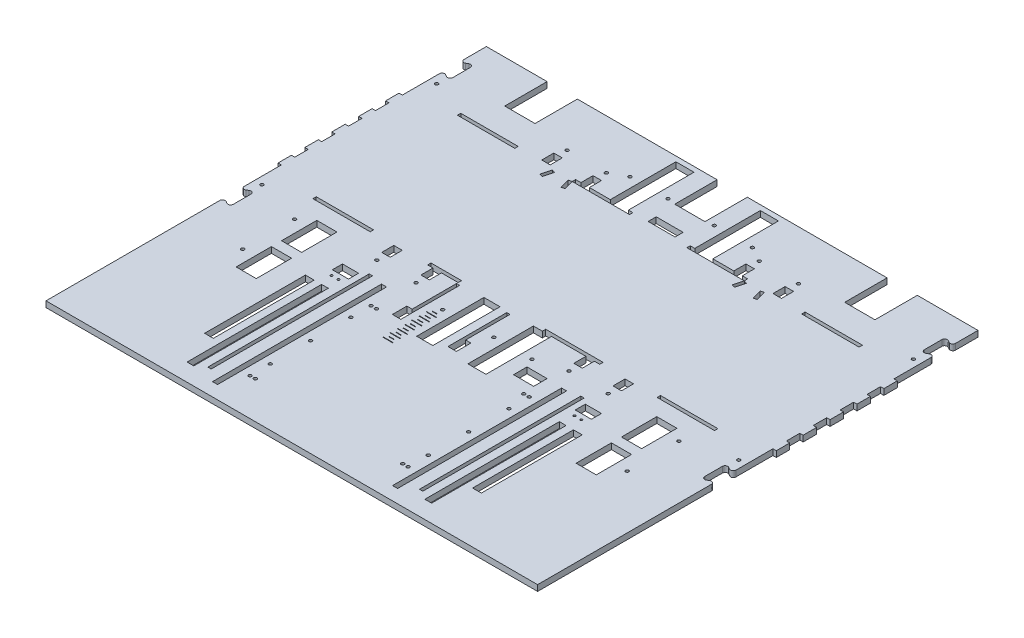
from build123d import *

# Parameters (mm, degrees)
SKETCH1_W                  = 54.186666667
SKETCH1_H                  = 3.175
SKETCH1_W_2                = 54.186666666
SKETCH1_W_3                = 3.175
SKETCH1_H_2                = 12.7
MAIN_EXTRUDE_DEPTH         = 5.588
SKETCH3_W                  = 25.484666667
SKETCH3_H                  = 3.175
UNDER_TROUGH_FILL_DEPTH    = 5.588
SKETCH4_R                  = 1.499997
SKETCH4_W                  = 12.7
SKETCH4_H                  = 3.175
SKETCH4_W_2                = 17.1
SKETCH4_H_2                = 61.9125
LEVER_HOLES_DEPTH          = 6.588
SKETCH5_W                  = 15.24
SKETCH5_H                  = 63.5
SKETCH5_W_2                = 0.15
SKETCH5_H_2                = 3.175
SKETCH5_R                  = 1.5
TROUGH_SLOT_DEPTH          = 6.588
SKETCH6_R                  = 1.05
SKETCH6_W                  = 15.24
SKETCH6_H                  = 9.525
CLOSE_SWITCH_HOLES_DEPTH   = 6.588
SKETCH7_W                  = 9.525
SKETCH7_H                  = 0.508
SKETCH7_W_2                = 4.7625
TROUGH_MEASUREMENT_DEPTH   = 6.588
SKETCH8_W                  = 19.05
SKETCH8_H                  = 33.3375
SKETCH8_H_2                = 12.7
SKETCH8_W_2                = 28.575
SKETCH8_H_3                = 40
SKETCH8_W_3                = 25.4
SKETCH8_H_4                = 7.62
WIRE_HOLES_DEPTH           = 6.588
SKETCH9_R                  = 1.5
SKETCH9_W                  = 8
SKETCH9_H                  = 11.43
IR_SLOTS_DEPTH             = 6.588
DOOR_FLANGE_SLOTS_DEPTH    = 6.588
SKETCH12_R                 = 1.5
SKETCH12_W                 = 3.175
SKETCH12_H                 = 12.7
FLOOR_MOUNT_HOLES_DEPTH    = 6.588
EXTENSION_CENTER_CUT_DEPTH = 6.588
SKETCH13_W                 = 464.2612
SKETCH13_H                 = 114.3
CENTER_EXTEND_DEPTH        = 5.588
SKETCH15_W                 = 3.175
SKETCH15_H                 = 152.4
TRACK_CUTS_DEPTH           = 6.588
SKETCH18_R                 = 1.5
SKETCH18_W                 = 4.7752
SKETCH18_H                 = 159.639
SERVO_RACK_HOLES_DEPTH     = 6.588
SKETCH17_W                 = 8.255
SKETCH17_H                 = 95.25
SKETCH17_W_2               = 6.35
SKETCH17_H_2               = 127
SERVO_WIRE_CUTS_DEPTH      = 6.588
SKETCH19_R                 = 1.5
PI_MOUNT_HOLES_DEPTH       = 6.588
SKETCH20_R                 = 1.5
SKETCH20_W                 = 8
SKETCH20_H                 = 11.43
IR2_DEPTH                  = 5.588


with BuildPart() as part:
    # Sketch1 → Main Extrude (new body)
    with BuildSketch(Plane(origin=(0, 0, 0), x_dir=(1, 0, 0), z_dir=(0, 1, 0))):
        Polygon((406.4, 136.525), (-406.4, 136.525), (-406.4, 69.85), (-352.213333333, 69.85), (-352.213333333, 66.675), (-377.825, 66.675), (-377.825, 57.15), (-381, 57.15), (-381, 66.675), (-406.4, 66.675), (-406.4, -66.675), (-381, -66.675), (-381, -57.15), (-377.825, -57.15), (-377.825, -66.675), (-352.213333333, -66.675), (-352.213333333, -69.85), (-406.4, -69.85), (-406.4, -165.1), (406.4, -165.1), (406.4, -69.85), (352.213333333, -69.85), (352.213333333, -66.675), (377.825, -66.675), (377.825, -57.15), (381, -57.15), (381, -66.675), (406.4, -66.675), (406.4, 66.675), (381, 66.675), (381, 57.15), (377.825, 57.15), (377.825, 66.675), (352.213333333, 66.675), (352.213333333, 69.85), (406.4, 69.85), align=None)
        with Locations((270.933333334, -68.2625)):
            Rectangle(SKETCH1_W, SKETCH1_H, mode=Mode.SUBTRACT)
        with Locations((162.56, -68.2625)):
            Rectangle(SKETCH1_W_2, SKETCH1_H, mode=Mode.SUBTRACT)
        with Locations((54.186666667, -68.2625)):
            Rectangle(SKETCH1_W, SKETCH1_H, mode=Mode.SUBTRACT)
        with Locations((-54.186666667, -68.2625)):
            Rectangle(SKETCH1_W, SKETCH1_H, mode=Mode.SUBTRACT)
        with Locations((-162.56, -68.2625)):
            Rectangle(SKETCH1_W_2, SKETCH1_H, mode=Mode.SUBTRACT)
        with Locations((-270.933333334, -68.2625)):
            Rectangle(SKETCH1_W, SKETCH1_H, mode=Mode.SUBTRACT)
        with Locations((379.4125, -38.1)):
            Rectangle(SKETCH1_W_3, SKETCH1_H_2, mode=Mode.SUBTRACT)
        with Locations((379.4125, -12.7)):
            Rectangle(SKETCH1_W_3, SKETCH1_H_2, mode=Mode.SUBTRACT)
        with Locations((379.4125, 12.7)):
            Rectangle(SKETCH1_W_3, SKETCH1_H_2, mode=Mode.SUBTRACT)
        with Locations((379.4125, 38.1)):
            Rectangle(SKETCH1_W_3, SKETCH1_H_2, mode=Mode.SUBTRACT)
        with Locations((-379.4125, -38.1)):
            Rectangle(SKETCH1_W_3, SKETCH1_H_2, mode=Mode.SUBTRACT)
        with Locations((-379.4125, -12.7)):
            Rectangle(SKETCH1_W_3, SKETCH1_H_2, mode=Mode.SUBTRACT)
        with Locations((-379.4125, 12.7)):
            Rectangle(SKETCH1_W_3, SKETCH1_H_2, mode=Mode.SUBTRACT)
        with Locations((-379.4125, 38.1)):
            Rectangle(SKETCH1_W_3, SKETCH1_H_2, mode=Mode.SUBTRACT)
        with Locations((270.933333334, 68.2625)):
            Rectangle(SKETCH1_W, SKETCH1_H, mode=Mode.SUBTRACT)
        with Locations((162.56, 68.2625)):
            Rectangle(SKETCH1_W_2, SKETCH1_H, mode=Mode.SUBTRACT)
        with Locations((54.186666667, 68.2625)):
            Rectangle(SKETCH1_W, SKETCH1_H, mode=Mode.SUBTRACT)
        with Locations((-54.186666667, 68.2625)):
            Rectangle(SKETCH1_W, SKETCH1_H, mode=Mode.SUBTRACT)
        with Locations((-162.56, 68.2625)):
            Rectangle(SKETCH1_W_2, SKETCH1_H, mode=Mode.SUBTRACT)
        with Locations((-270.933333334, 68.2625)):
            Rectangle(SKETCH1_W, SKETCH1_H, mode=Mode.SUBTRACT)
    extrude(amount=MAIN_EXTRUDE_DEPTH)

    # Sketch3 → Under Trough Fill (add)
    with BuildSketch(Plane(origin=(0, 5.588, 0), x_dir=(1, 0, 0), z_dir=(0, 1, 0))):
        with Locations((-39.835666667, -68.2625)):
            Rectangle(SKETCH3_W, SKETCH3_H)
    extrude(amount=-UNDER_TROUGH_FILL_DEPTH)

    # Sketch4 → Lever Holes (cut, through all)
    with BuildSketch(Plane(origin=(0, 5.588, 0), x_dir=(1, 0, 0), z_dir=(0, 1, 0))):
        with Locations((9.178, -97.7625)):
            Circle(SKETCH4_R)
        with Locations((45.178, -97.7625)):
            Circle(SKETCH4_R)
        with Locations((21.878, 97.7625)):
            Circle(SKETCH4_R)
        with Locations((57.878, 97.7625)):
            Circle(SKETCH4_R)
        with Locations((-21.878, 97.7625)):
            Circle(SKETCH4_R)
        with Locations((-57.878, 97.7625)):
            Circle(SKETCH4_R)
        with Locations((-393.7, -65.0875)):
            Rectangle(SKETCH4_W, SKETCH4_H)
        with Locations((-393.7, 65.0875)):
            Rectangle(SKETCH4_W, SKETCH4_H)
        with Locations((393.7, 65.0875)):
            Rectangle(SKETCH4_W, SKETCH4_H)
        with Locations((393.7, -65.0875)):
            Rectangle(SKETCH4_W, SKETCH4_H)
        with Locations((27.178, -100.80625)):
            Rectangle(SKETCH4_W_2, SKETCH4_H_2)
        with Locations((39.878, 100.80625)):
            Rectangle(SKETCH4_W_2, SKETCH4_H_2)
        with Locations((-39.878, 100.80625)):
            Rectangle(SKETCH4_W_2, SKETCH4_H_2)
    extrude(amount=-LEVER_HOLES_DEPTH, mode=Mode.SUBTRACT)

    # Sketch5 → Trough Slot (cut, through all)
    with BuildSketch(Plane(origin=(0, 5.588, 0), x_dir=(1, 0, 0), z_dir=(0, 1, 0))):
        Polygon((-52.428, -71.4248), (-52.428, -113.3), (-57.428, -113.3), (-57.428, -127), (-49.428, -127), (-49.428, -71.4248), align=None)
        Polygon((-4.928, -127), (3.072, -127), (3.072, -113.3), (-1.928, -113.3), (-1.928, -71.4248), (-4.928, -71.4248), align=None)
        with Locations((-20.498, -101.6)):
            Rectangle(SKETCH5_W, SKETCH5_H)
        with Locations((-52.503, -68.2625)):
            Rectangle(SKETCH5_W_2, SKETCH5_H_2)
        with Locations((-37.568, -99.35)):
            Circle(SKETCH5_R)
    extrude(amount=-TROUGH_SLOT_DEPTH, mode=Mode.SUBTRACT)

    # Sketch6 → Close Switch Holes (cut, through all)
    with BuildSketch(Plane(origin=(0, 5.588, 0), x_dir=(1, 0, 0), z_dir=(0, 1, 0))):
        with Locations((117.9405058, -123.8499876)):
            Circle(SKETCH6_R)
        with Locations((111.4404934, -123.8499876)):
            Circle(SKETCH6_R)
        with Locations((-117.9405058, -123.8499876)):
            Circle(SKETCH6_R)
        with Locations((-111.4404934, -123.8499876)):
            Circle(SKETCH6_R)
        with Locations((-114.6904996, -114.0074876)):
            Rectangle(SKETCH6_W, SKETCH6_H)
        with Locations((114.6904996, -114.0074876)):
            Rectangle(SKETCH6_W, SKETCH6_H)
    extrude(amount=-CLOSE_SWITCH_HOLES_DEPTH, mode=Mode.SUBTRACT)

    # Sketch7 → Trough Measurement (cut, through all)
    with BuildSketch(Plane(origin=(0, 5.588, 0), x_dir=(1, 0, 0), z_dir=(0, 1, 0))):
        with Locations((-38.773, -142.992)):
            Rectangle(SKETCH7_W, SKETCH7_H)
        with Locations((-38.773, -149.85)):
            Rectangle(SKETCH7_W, SKETCH7_H)
        with Locations((-38.773, -146.675)):
            Rectangle(SKETCH7_W_2, SKETCH7_H)
        with Locations((-38.773, -139.817)):
            Rectangle(SKETCH7_W_2, SKETCH7_H)
        with Locations((-38.773, -136.134)):
            Rectangle(SKETCH7_W, SKETCH7_H)
        with Locations((-38.773, -132.959)):
            Rectangle(SKETCH7_W_2, SKETCH7_H)
        with Locations((-38.773, -129.276)):
            Rectangle(SKETCH7_W, SKETCH7_H)
        with Locations((-38.773, -126.101)):
            Rectangle(SKETCH7_W_2, SKETCH7_H)
        with Locations((-38.773, -122.418)):
            Rectangle(SKETCH7_W, SKETCH7_H)
        with Locations((-38.773, -119.243)):
            Rectangle(SKETCH7_W_2, SKETCH7_H)
        with Locations((-38.773, -115.56)):
            Rectangle(SKETCH7_W, SKETCH7_H)
        with Locations((-38.773, -112.385)):
            Rectangle(SKETCH7_W_2, SKETCH7_H)
        with Locations((-38.773, -108.702)):
            Rectangle(SKETCH7_W, SKETCH7_H)
        with Locations((-38.773, -105.527)):
            Rectangle(SKETCH7_W_2, SKETCH7_H)
    extrude(amount=-TROUGH_MEASUREMENT_DEPTH, mode=Mode.SUBTRACT)

    # Sketch8 → Wire Holes (cut, through all)
    with BuildSketch(Plane(origin=(0, 5.588, 0), x_dir=(1, 0, 0), z_dir=(0, 1, 0))):
        with Locations((-160.528, -145.25625)):
            Rectangle(SKETCH8_W, SKETCH8_H)
        with Locations((-160.528, -102.39375)):
            Rectangle(SKETCH8_W, SKETCH8_H)
        with Locations((160.528, -145.25625)):
            Rectangle(SKETCH8_W, SKETCH8_H)
        with Locations((160.528, -102.39375)):
            Rectangle(SKETCH8_W, SKETCH8_H)
        with Locations((58.588, -112.7125)):
            Rectangle(SKETCH8_W, SKETCH8_H_2)
        with Locations((0, 116.525)):
            Rectangle(SKETCH8_W_2, SKETCH8_H_3)
        with Locations((0, 73.66)):
            Rectangle(SKETCH8_W_3, SKETCH8_H_4)
        with Locations((-160.528, 116.525)):
            Rectangle(SKETCH8_W_2, SKETCH8_H_3)
        with Locations((160.528, 116.525)):
            Rectangle(SKETCH8_W_2, SKETCH8_H_3)
    extrude(amount=-WIRE_HOLES_DEPTH, mode=Mode.SUBTRACT)

    # Sketch9 → IR Slots (cut, through all)
    with BuildSketch(Plane(origin=(0, 5.588, 0), x_dir=(1, 0, 0), z_dir=(0, 1, 0))):
        with Locations((109.2096114, -89.85)):
            Circle(SKETCH9_R)
        with Locations((-109.2096114, -89.85)):
            Circle(SKETCH9_R)
        with Locations((109.2096114, 89.85)):
            Circle(SKETCH9_R)
        with Locations((-109.2096114, 89.85)):
            Circle(SKETCH9_R)
        with Locations((-109.2096114, 75.565)):
            Rectangle(SKETCH9_W, SKETCH9_H)
        with Locations((109.2096114, 75.565)):
            Rectangle(SKETCH9_W, SKETCH9_H)
        with Locations((109.2096114, -75.565)):
            Rectangle(SKETCH9_W, SKETCH9_H)
        with Locations((-109.2096114, -75.565)):
            Rectangle(SKETCH9_W, SKETCH9_H)
    extrude(amount=-IR_SLOTS_DEPTH, mode=Mode.SUBTRACT)

    # Sketch10 → Door Flange Slots (cut, through all)
    with BuildSketch(Plane(origin=(0, 5.588, 0), x_dir=(1, 0, 0), z_dir=(0, 1, 0))):
        Polygon((-100.061001873, 66.675), (-96.994187374, 65.853249532), (-99.459438779, 56.652806036), (-102.526253277, 57.474556505), align=None)
        Polygon((-84.361812626, 65.853249532), (-81.294998127, 66.675), (-78.829746723, 57.474556505), (-81.896561221, 56.652806036), align=None)
        Polygon((81.294998127, 66.675), (78.829746723, 57.474556505), (81.896561221, 56.652806036), (84.361812626, 65.853249532), align=None)
        Polygon((96.994187374, 65.853249532), (99.459438779, 56.652806036), (102.526253277, 57.474556505), (100.061001873, 66.675), align=None)
    extrude(amount=-DOOR_FLANGE_SLOTS_DEPTH, mode=Mode.SUBTRACT)

    # Sketch12 → Floor Mount Holes (cut, through all)
    with BuildSketch(Plane(origin=(0, 5.588, 0), x_dir=(1, 0, 0), z_dir=(0, 1, 0))):
        with Locations((-253.58725, -82.55)):
            Circle(SKETCH12_R)
        with Locations((-225.13925, -82.55)):
            Circle(SKETCH12_R)
        with Locations((-253.58725, 82.55)):
            Circle(SKETCH12_R)
        with Locations((-225.13925, 82.55)):
            Circle(SKETCH12_R)
        with Locations((225.13925, 82.55)):
            Circle(SKETCH12_R)
        with Locations((253.58725, 82.55)):
            Circle(SKETCH12_R)
        with Locations((225.13925, -82.55)):
            Circle(SKETCH12_R)
        with Locations((253.58725, -82.55)):
            Circle(SKETCH12_R)
        with Locations((-239.36325, -82.55)):
            Rectangle(SKETCH12_W, SKETCH12_H)
        with Locations((-239.36325, 82.55)):
            Rectangle(SKETCH12_W, SKETCH12_H)
        with Locations((239.36325, 82.55)):
            Rectangle(SKETCH12_W, SKETCH12_H)
        with Locations((239.36325, -82.55)):
            Rectangle(SKETCH12_W, SKETCH12_H)
    extrude(amount=-FLOOR_MOUNT_HOLES_DEPTH, mode=Mode.SUBTRACT)

    # Sketch11_3 → Extension Center Cut (cut, through all)
    with BuildSketch(Plane(origin=(0, 5.588, 0), x_dir=(1, 0, 0), z_dir=(0, 1, 0))):
        with BuildLine():
            Line((-232.1306, 57.15), (-232.1306, 92.075))
            ThreePointArc((-232.1306, 92.075), (-230.8606, 94.274704526), (-228.3206, 94.274704526))
            Line((-228.3206, 94.274704526), (-226.4156, 93.174852263))
            ThreePointArc((-226.4156, 93.174852263), (-223.8756, 93.174852263), (-222.6056, 95.374556788))
            Line((-222.6056, 95.374556788), (-222.6056, 111.975738686))
            ThreePointArc((-222.6056, 111.975738686), (-223.8756, 114.175443212), (-226.4156, 114.175443212))
            Line((-226.4156, 114.175443212), (-228.3206, 113.075590949))
            ThreePointArc((-228.3206, 113.075590949), (-230.8606, 113.075590949), (-232.1306, 115.275295474))
            Line((-232.1306, 115.275295474), (-232.1306, 136.525))
            Line((-232.1306, 136.525), (-406.4, 136.525))
            Line((-406.4, 136.525), (-406.4, -165.1))
            Line((-406.4, -165.1), (-232.1306, -165.1))
            Line((-232.1306, -165.1), (-232.1306, -115.275295474))
            ThreePointArc((-232.1306, -115.275295474), (-230.8606, -113.075590949), (-228.3206, -113.075590949))
            Line((-228.3206, -113.075590949), (-226.4156, -114.175443212))
            ThreePointArc((-226.4156, -114.175443212), (-223.8756, -114.175443212), (-222.6056, -111.975738686))
            Line((-222.6056, -111.975738686), (-222.6056, -95.374556788))
            ThreePointArc((-222.6056, -95.374556788), (-223.8756, -93.174852263), (-226.4156, -93.174852263))
            Line((-226.4156, -93.174852263), (-228.3206, -94.274704526))
            ThreePointArc((-228.3206, -94.274704526), (-230.8606, -94.274704526), (-232.1306, -92.075))
            Line((-232.1306, -92.075), (-232.1306, -57.15))
            Line((-232.1306, -57.15), (-235.3056, -57.15))
            Line((-235.3056, -57.15), (-235.3056, -44.45))
            Line((-235.3056, -44.45), (-232.1306, -44.45))
            Line((-232.1306, -44.45), (-232.1306, -31.75))
            Line((-232.1306, -31.75), (-235.3056, -31.75))
            Line((-235.3056, -31.75), (-235.3056, -19.05))
            Line((-235.3056, -19.05), (-232.1306, -19.05))
            Line((-232.1306, -19.05), (-232.1306, -6.35))
            Line((-232.1306, -6.35), (-235.3056, -6.35))
            Line((-235.3056, -6.35), (-235.3056, 6.35))
            Line((-235.3056, 6.35), (-232.1306, 6.35))
            Line((-232.1306, 6.35), (-232.1306, 19.05))
            Line((-232.1306, 19.05), (-235.3056, 19.05))
            Line((-235.3056, 19.05), (-235.3056, 31.75))
            Line((-235.3056, 31.75), (-232.1306, 31.75))
            Line((-232.1306, 31.75), (-232.1306, 44.45))
            Line((-232.1306, 44.45), (-235.3056, 44.45))
            Line((-235.3056, 44.45), (-235.3056, 57.15))
            Line((-235.3056, 57.15), (-232.1306, 57.15))
        make_face()
        with BuildLine():
            Line((406.4, 136.525), (232.1306, 136.525))
            Line((232.1306, 136.525), (232.1306, 115.275295474))
            ThreePointArc((232.1306, 115.275295474), (230.8606, 113.075590949), (228.3206, 113.075590949))
            Line((228.3206, 113.075590949), (226.4156, 114.175443212))
            ThreePointArc((226.4156, 114.175443212), (223.8756, 114.175443212), (222.6056, 111.975738686))
            Line((222.6056, 111.975738686), (222.6056, 95.374556788))
            ThreePointArc((222.6056, 95.374556788), (223.8756, 93.174852263), (226.4156, 93.174852263))
            Line((226.4156, 93.174852263), (228.3206, 94.274704526))
            ThreePointArc((228.3206, 94.274704526), (230.8606, 94.274704526), (232.1306, 92.075))
            Line((232.1306, 92.075), (232.1306, 57.15))
            Line((232.1306, 57.15), (235.3056, 57.15))
            Line((235.3056, 57.15), (235.3056, 44.45))
            Line((235.3056, 44.45), (232.1306, 44.45))
            Line((232.1306, 44.45), (232.1306, 31.75))
            Line((232.1306, 31.75), (235.3056, 31.75))
            Line((235.3056, 31.75), (235.3056, 19.05))
            Line((235.3056, 19.05), (232.1306, 19.05))
            Line((232.1306, 19.05), (232.1306, 6.35))
            Line((232.1306, 6.35), (235.3056, 6.35))
            Line((235.3056, 6.35), (235.3056, -6.35))
            Line((235.3056, -6.35), (232.1306, -6.35))
            Line((232.1306, -6.35), (232.1306, -19.05))
            Line((232.1306, -19.05), (235.3056, -19.05))
            Line((235.3056, -19.05), (235.3056, -31.75))
            Line((235.3056, -31.75), (232.1306, -31.75))
            Line((232.1306, -31.75), (232.1306, -44.45))
            Line((232.1306, -44.45), (235.3056, -44.45))
            Line((235.3056, -44.45), (235.3056, -57.15))
            Line((235.3056, -57.15), (232.1306, -57.15))
            Line((232.1306, -57.15), (232.1306, -92.075))
            ThreePointArc((232.1306, -92.075), (230.8606, -94.274704526), (228.3206, -94.274704526))
            Line((228.3206, -94.274704526), (226.4156, -93.174852263))
            ThreePointArc((226.4156, -93.174852263), (223.8756, -93.174852263), (222.6056, -95.374556788))
            Line((222.6056, -95.374556788), (222.6056, -111.975738686))
            ThreePointArc((222.6056, -111.975738686), (223.8756, -114.175443212), (226.4156, -114.175443212))
            Line((226.4156, -114.175443212), (228.3206, -113.075590949))
            ThreePointArc((228.3206, -113.075590949), (230.8606, -113.075590949), (232.1306, -115.275295474))
            Line((232.1306, -115.275295474), (232.1306, -165.1))
            Line((232.1306, -165.1), (406.4, -165.1))
            Line((406.4, -165.1), (406.4, 136.525))
        make_face()
    extrude(amount=-EXTENSION_CENTER_CUT_DEPTH, mode=Mode.SUBTRACT)

    # Sketch13 → Center Extend (add)
    with BuildSketch(Plane(origin=(0, 5.588, 0), x_dir=(1, 0, 0), z_dir=(0, 1, 0))):
        with Locations((0, -222.25)):
            Rectangle(SKETCH13_W, SKETCH13_H)
    extrude(amount=-CENTER_EXTEND_DEPTH)

    # Sketch15 → Track Cuts (cut, through all)
    with BuildSketch(Plane(origin=(0, 5.588, 0), x_dir=(1, 0, 0), z_dir=(0, 1, 0))):
        with Locations((99.928, -180.975)):
            Rectangle(SKETCH15_W, SKETCH15_H)
        with Locations((-99.928, -180.975)):
            Rectangle(SKETCH15_W, SKETCH15_H)
    extrude(amount=-TRACK_CUTS_DEPTH, mode=Mode.SUBTRACT)

    # Sketch18 → Servo Rack Holes (cut, through all)
    with BuildSketch(Plane(origin=(0, 5.588, 0), x_dir=(1, 0, 0), z_dir=(0, 1, 0))):
        with Locations((-69.6103, -129.921)):
            Circle(SKETCH18_R)
        with Locations((-69.6103, -244.221)):
            Circle(SKETCH18_R)
        with Locations((-74.63315, -187.071)):
            Circle(SKETCH18_R)
        with Locations((74.63315, -187.071)):
            Circle(SKETCH18_R)
        with Locations((69.6103, -244.221)):
            Circle(SKETCH18_R)
        with Locations((69.6103, -129.921)):
            Circle(SKETCH18_R)
        with Locations((-74.63315, -225.171)):
            Circle(SKETCH18_R)
        with Locations((-74.63315, -148.971)):
            Circle(SKETCH18_R)
        with Locations((74.63315, -225.171)):
            Circle(SKETCH18_R)
        with Locations((74.63315, -148.971)):
            Circle(SKETCH18_R)
        with Locations((-74.63315, -244.221)):
            Circle(SKETCH18_R)
        with Locations((-74.63315, -129.921)):
            Circle(SKETCH18_R)
        with Locations((74.63315, -244.221)):
            Circle(SKETCH18_R)
        with Locations((74.63315, -129.921)):
            Circle(SKETCH18_R)
        with Locations((-85.0154, -187.071)):
            Rectangle(SKETCH18_W, SKETCH18_H)
        with Locations((85.0154, -187.071)):
            Rectangle(SKETCH18_W, SKETCH18_H)
    extrude(amount=-SERVO_RACK_HOLES_DEPTH, mode=Mode.SUBTRACT)

    # Sketch17 → Servo Wire Cuts (cut, through all)
    with BuildSketch(Plane(origin=(0, 5.588, 0), x_dir=(1, 0, 0), z_dir=(0, 1, 0))):
        with Locations((126.5555, -183.4515)):
            Rectangle(SKETCH17_W, SKETCH17_H)
        with Locations((112.268, -199.3265)):
            Rectangle(SKETCH17_W_2, SKETCH17_H_2)
        with Locations((-126.5555, -183.4515)):
            Rectangle(SKETCH17_W, SKETCH17_H)
        with Locations((-112.268, -199.3265)):
            Rectangle(SKETCH17_W_2, SKETCH17_H_2)
    extrude(amount=-SERVO_WIRE_CUTS_DEPTH, mode=Mode.SUBTRACT)

    # Sketch19 → Pi Mount Holes (cut, through all)
    with BuildSketch(Plane(origin=(0, 5.588, 0), x_dir=(1, 0, 0), z_dir=(0, 1, 0))):
        with Locations((181.483, -95.25)):
            Circle(SKETCH19_R)
        with Locations((239.483, -95.25)):
            Circle(SKETCH19_R)
        with Locations((239.483, -144.25)):
            Circle(SKETCH19_R)
        with Locations((181.483, -144.25)):
            Circle(SKETCH19_R)
        with Locations((-239.483, -144.25)):
            Circle(SKETCH19_R)
        with Locations((-239.483, -95.25)):
            Circle(SKETCH19_R)
        with Locations((-181.483, -144.25)):
            Circle(SKETCH19_R)
        with Locations((-181.483, -95.25)):
            Circle(SKETCH19_R)
    extrude(amount=-PI_MOUNT_HOLES_DEPTH, mode=Mode.SUBTRACT)

    # Sketch20 → IR2 (cut)
    with BuildSketch(Plane(origin=(0, 5.588, 0), x_dir=(1, 0, 0), z_dir=(0, 1, 0))):
        with Locations((-72.2096114, -89.85)):
            Circle(SKETCH20_R)
        with Locations((-72.2096114, 89.85)):
            Circle(SKETCH20_R)
        with Locations((72.2096114, -89.85)):
            Circle(SKETCH20_R)
        with Locations((72.2096114, 89.85)):
            Circle(SKETCH20_R)
        with Locations((-72.2096114, -75.565)):
            Rectangle(SKETCH20_W, SKETCH20_H)
        with Locations((-72.2096114, 75.565)):
            Rectangle(SKETCH20_W, SKETCH20_H)
        with Locations((72.2096114, -75.565)):
            Rectangle(SKETCH20_W, SKETCH20_H)
        with Locations((72.2096114, 75.565)):
            Rectangle(SKETCH20_W, SKETCH20_H)
    extrude(amount=-IR2_DEPTH, mode=Mode.SUBTRACT)


solid = part.part
